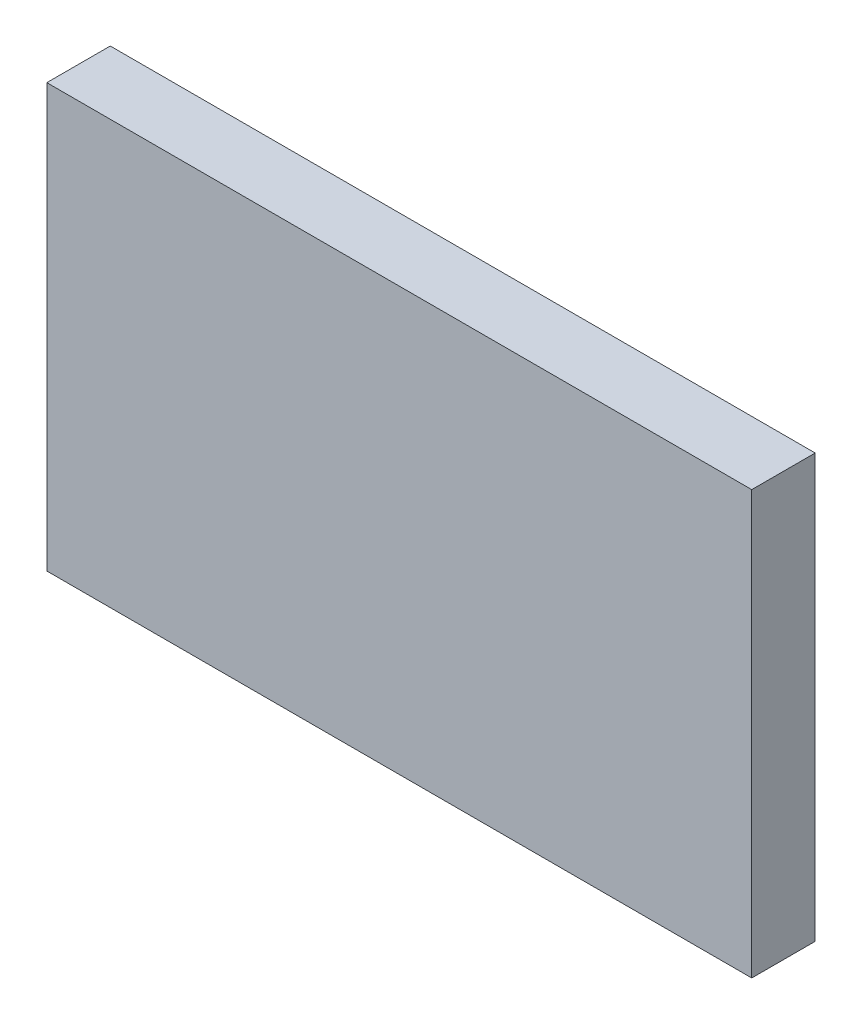
from build123d import *

# Parameters (mm, degrees)
SKETCH1_W           = 100
SKETCH1_H           = 60
BOSS_EXTRUDE1_DEPTH = 9


with BuildPart() as part:
    # Sketch1 → Boss-Extrude1 (new body)
    with BuildSketch(Plane.XY):
        with Locations((16.143106457, 1.413612565)):
            Rectangle(SKETCH1_W, SKETCH1_H)
    extrude(amount=BOSS_EXTRUDE1_DEPTH)


solid = part.part
